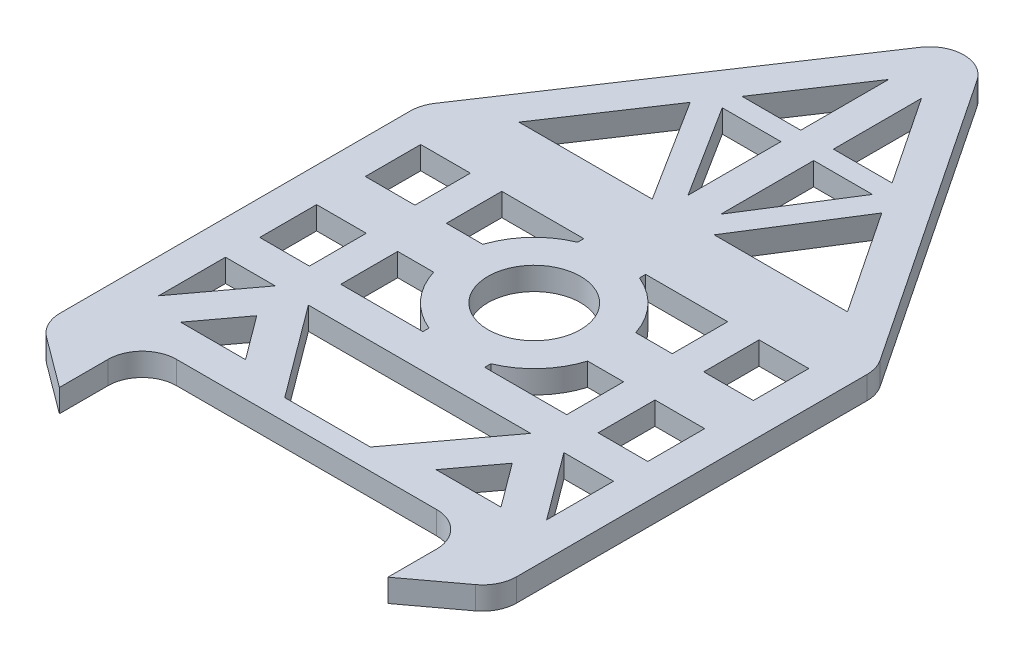
from build123d import *

# Parameters (mm, degrees)
SKETCH1_R           = 40.52203667
SKETCH1_W           = 43.509433639
SKETCH1_H           = 49.835103658
SKETCH1_H_2         = 48.542170344
SKETCH1_W_2         = 43.509433638
BOSS_EXTRUDE6_DEPTH = 20
FILLET1_R           = 30
FILLET2_R           = 30


with BuildPart() as part:
    # Sketch1 → Boss-Extrude6 (new body)
    with BuildSketch(Plane(origin=(0, 0, 0), x_dir=(1, 0, 0), z_dir=(0, 1, 0))):
        Polygon((-324.500042801, 0), (-36.61106831, 0), (-36.61106831, -72.630227613), (19.444444444, -30.98937664), (19.444444444, 0), (19.444444444, 300), (-180.555555556, 600), (-380.555555556, 300), (-380.555555556, 0), (-380.555555556, -30.98937664), (-324.500042801, -72.630227613), align=None)
        with Locations((-180.555555556, 199.47796333)):
            Circle(SKETCH1_R, mode=Mode.SUBTRACT)
        Polygon((-350.555555556, 98.955926659), (-307.046121917, 98.955926659), (-350.555555556, 40.384990781), align=None, mode=Mode.SUBTRACT)
        Polygon((-218.052993309, 18.381237109), (-277.907920592, 98.955926659), (-83.203190519, 98.955926659), (-143.058117802, 18.381237109), align=None, mode=Mode.SUBTRACT)
        Polygon((-40.212760909, 30), (-97.055418804, 30), (-68.634089856, 68.259836918), align=None, mode=Mode.SUBTRACT)
        with Locations((-328.800838736, 153.873478488)):
            Rectangle(SKETCH1_W, SKETCH1_H, mode=Mode.SUBTRACT)
        Polygon((-194.895952536, 524.406135398), (-246.308768225, 447.286911864), (-194.895952536, 447.286911864), align=None, mode=Mode.SUBTRACT)
        Polygon((-36.61106831, 330), (-96.633315679, 420.033371054), (-153.463987032, 330), align=None, mode=Mode.SUBTRACT)
        Polygon((-324.500042801, 330), (-207.64712408, 330), (-264.477795432, 420.033371054), align=None, mode=Mode.SUBTRACT)
        Polygon((-10.555555556, 40.384990781), (-54.064989194, 98.955926659), (-10.555555556, 98.955926659), align=None, mode=Mode.SUBTRACT)
        with Locations((-328.800838736, 245.728914828)):
            Rectangle(SKETCH1_W, SKETCH1_H_2, mode=Mode.SUBTRACT)
        with Locations((-32.310272375, 153.873478488)):
            Rectangle(SKETCH1_W_2, SKETCH1_H, mode=Mode.SUBTRACT)
        Polygon((-320.898350202, 30), (-264.055692307, 30), (-292.477021255, 68.259836918), align=None, mode=Mode.SUBTRACT)
        with Locations((-32.310272375, 245.728914828)):
            Rectangle(SKETCH1_W_2, SKETCH1_H_2, mode=Mode.SUBTRACT)
        with BuildLine():
            Line((-279.511482215, 270), (-279.511482215, 221.457829656))
            Line((-279.511482215, 221.457829656), (-247.564832021, 221.457829656))
            ThreePointArc((-247.564832021, 221.457829656), (-232.312774166, 247.379403578), (-207.64712408, 264.58867344))
            Line((-207.64712408, 264.58867344), (-207.64712408, 270))
            Line((-207.64712408, 270), (-279.511482215, 270))
        make_face(mode=Mode.SUBTRACT)
        with BuildLine():
            Line((-279.511482215, 128.955926659), (-279.511482215, 178.791030317))
            Line((-279.511482215, 178.791030317), (-247.975200012, 178.791030317))
            ThreePointArc((-247.975200012, 178.791030317), (-232.771073725, 152.076514844), (-207.64712408, 134.367253219))
            Line((-207.64712408, 134.367253219), (-207.64712408, 128.955926659))
            Line((-207.64712408, 128.955926659), (-279.511482215, 128.955926659))
        make_face(mode=Mode.SUBTRACT)
        with BuildLine():
            Line((-153.463987032, 134.367253219), (-153.463987032, 128.955926659))
            Line((-153.463987032, 128.955926659), (-81.599628896, 128.955926659))
            Line((-81.599628896, 128.955926659), (-81.599628896, 178.791030317))
            Line((-81.599628896, 178.791030317), (-113.135911099, 178.791030317))
            ThreePointArc((-113.135911099, 178.791030317), (-128.340037386, 152.076514844), (-153.463987032, 134.367253219))
        make_face(mode=Mode.SUBTRACT)
        with BuildLine():
            Line((-153.463987032, 264.58867344), (-153.463987032, 270))
            Line((-153.463987032, 270), (-81.599628896, 270))
            Line((-81.599628896, 270), (-81.599628896, 221.457829656))
            Line((-81.599628896, 221.457829656), (-113.54627909, 221.457829656))
            ThreePointArc((-113.54627909, 221.457829656), (-128.798336945, 247.379403578), (-153.463987032, 264.58867344))
        make_face(mode=Mode.SUBTRACT)
        Polygon((-114.802342886, 429.992241235), (-166.215158575, 429.992241235), (-166.215158575, 348.542048906), align=None, mode=Mode.SUBTRACT)
        Polygon((-114.802342886, 447.286911864), (-166.215158575, 524.406135398), (-166.215158575, 447.286911864), align=None, mode=Mode.SUBTRACT)
        Polygon((-246.308768225, 429.992241235), (-194.895952536, 348.542048906), (-194.895952536, 429.992241235), align=None, mode=Mode.SUBTRACT)
    extrude(amount=BOSS_EXTRUDE6_DEPTH)

    # Fillet1
    fillet1_edges = [part.edges().sort_by_distance(p)[0] for p in [
        (-180.555555556, 10, -600),
    ]]
    fillet(fillet1_edges, radius=FILLET1_R)

    # Fillet2
    fillet2_edges = [part.edges().sort_by_distance(p)[0] for p in [
        (19.444444444, 10, 30.98937664),
        (-36.61106831, 10, 0),
        (-324.500042801, 10, 0),
        (-380.555555556, 10, 30.98937664),
        (-380.555555556, 10, -300),
        (19.444444444, 10, -300),
    ]]
    fillet(fillet2_edges, radius=FILLET2_R)


solid = part.part
